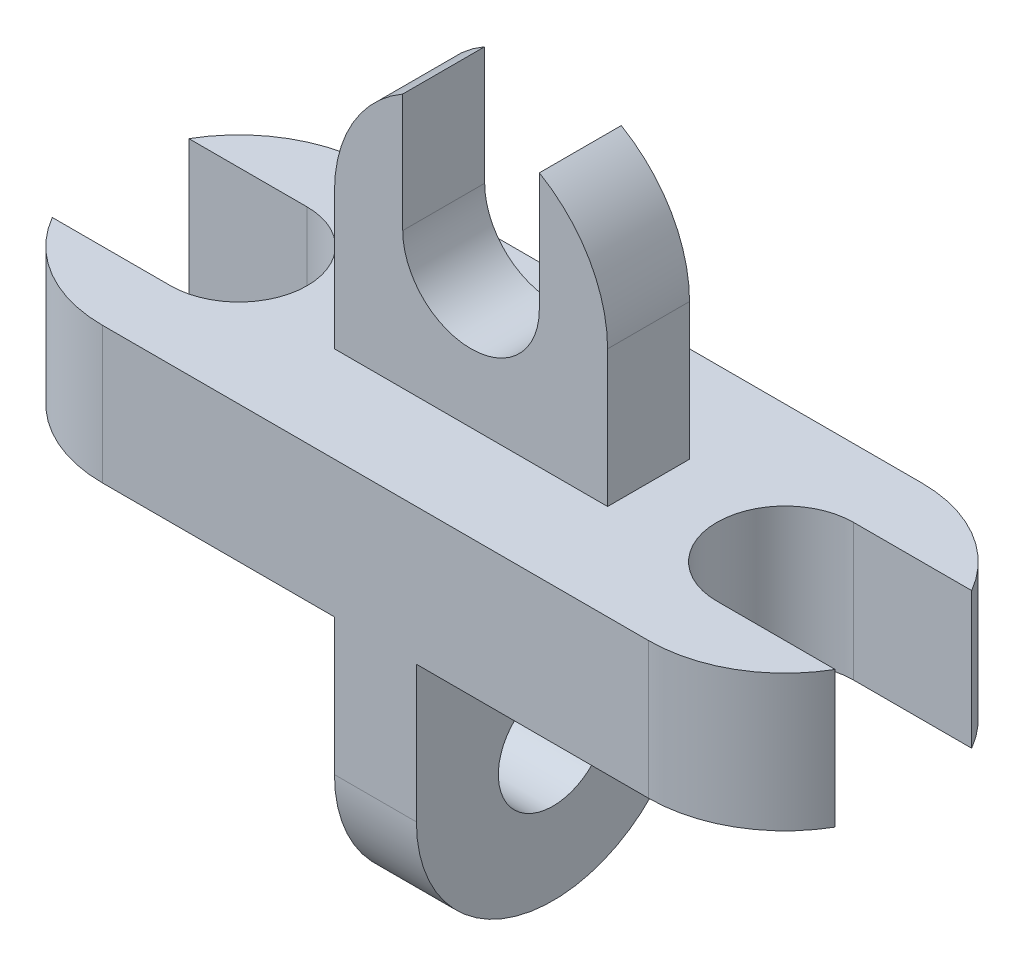
from build123d import *

# Parameters (mm, degrees)
BOSS_EXTRUDE1_DEPTH = 25
SKETCH2_W           = 100
SKETCH2_H           = 30
BOSS_EXTRUDE3_DEPTH = 150
CUT_EXTRUDE1_DEPTH  = 150
BOSS_EXTRUDE4_DEPTH = 15
SKETCH7_R           = 20
CUT_EXTRUDE2_DEPTH  = 30


with BuildPart() as part:
    # Sketch1 → Boss-Extrude1 (new body, symmetric)
    with BuildSketch(Plane(origin=(0, 0, 0), x_dir=(1, 0, 0), z_dir=(0, 1, 0))):
        with BuildLine():
            Line((100, 50), (-100, 50))
            ThreePointArc((-100, 50), (-125, 43.301270189), (-143.301270189, 25))
            Line((-143.301270189, 25), (-100, 25))
            ThreePointArc((-100, 25), (-75, 0), (-100, -25))
            Line((-100, -25), (-143.301270189, -25))
            ThreePointArc((-143.301270189, -25), (-125, -43.301270189), (-100, -50))
            Line((-100, -50), (100, -50))
            ThreePointArc((100, -50), (125, -43.301270189), (143.301270189, -25))
            Line((143.301270189, -25), (100, -25))
            ThreePointArc((100, -25), (75, 0), (100, 25))
            Line((100, 25), (143.301270189, 25))
            ThreePointArc((143.301270189, 25), (125, 43.301270189), (100, 50))
        make_face()
    extrude(amount=BOSS_EXTRUDE1_DEPTH, both=True)

    # Sketch2 → Boss-Extrude3 (add)
    with BuildSketch(Plane(origin=(0, 25, 0), x_dir=(1, 0, 0), z_dir=(0, 1, 0))):
        Rectangle(SKETCH2_W, SKETCH2_H)
    extrude(amount=BOSS_EXTRUDE3_DEPTH)

    # Sketch4 → Cut-Extrude1 (cut)
    with BuildSketch(Plane.XY.offset(15)):
        with BuildLine():
            Line((-25, 75), (-25, 118.301270189))
            ThreePointArc((-25, 118.301270189), (-43.301270189, 100), (-50, 75))
            Line((-50, 75), (-50, 175))
            Line((-50, 175), (50, 175))
            Line((50, 175), (50, 75))
            ThreePointArc((50, 75), (43.301270189, 100), (25, 118.301270189))
            Line((25, 118.301270189), (25, 75))
            ThreePointArc((25, 75), (0, 50), (-25, 75))
        make_face()
    extrude(amount=-CUT_EXTRUDE1_DEPTH, mode=Mode.SUBTRACT)

    # Sketch6 → Boss-Extrude4 (add, symmetric)
    with BuildSketch(Plane(origin=(0, 0, 0), x_dir=(0, 0, -1), z_dir=(1, 0, 0))):
        with BuildLine():
            Line((-50, -74.998729811), (-50, -25))
            Line((-50, -25), (-25, -25))
            Line((-25, -25), (25, -25))
            Line((25, -25), (50, -25))
            Line((50, -25), (50, -74.998729811))
            ThreePointArc((50, -74.998729811), (0, -124.998729811), (-50, -74.998729811))
        make_face()
    extrude(amount=BOSS_EXTRUDE4_DEPTH, both=True)

    # Sketch7 → Cut-Extrude2 (cut)
    with BuildSketch(Plane(origin=(15, 0, 0), x_dir=(0, 0, -1), z_dir=(1, 0, 0))):
        with Locations((0, -74.998729811)):
            Circle(SKETCH7_R)
    extrude(amount=-CUT_EXTRUDE2_DEPTH, mode=Mode.SUBTRACT)


solid = part.part
